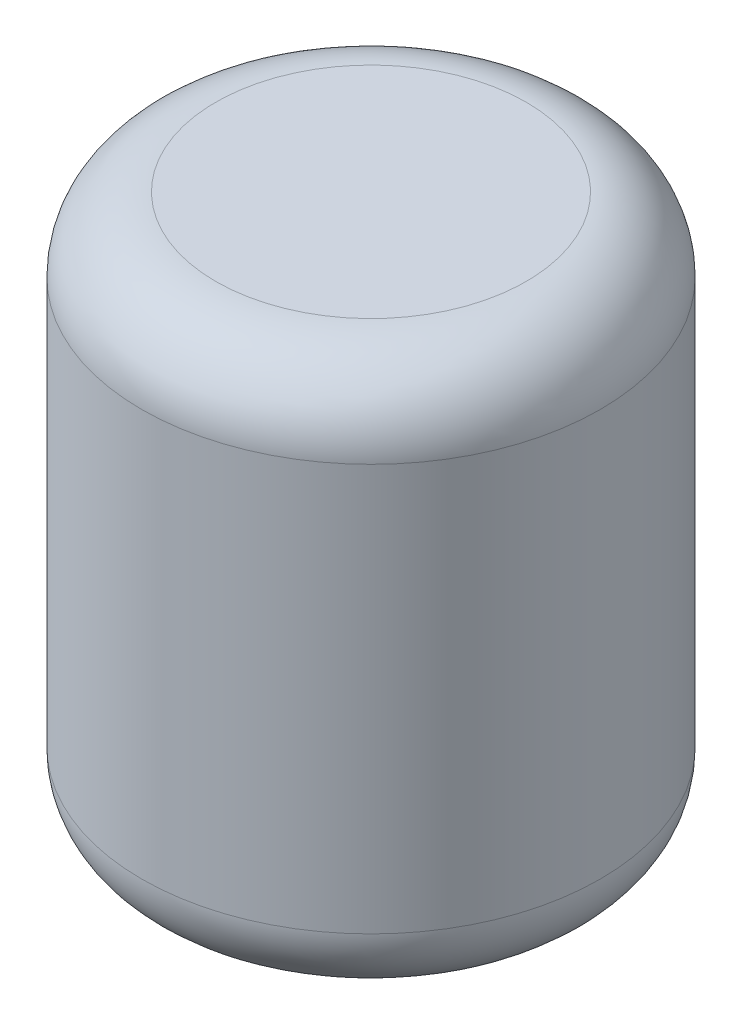
from build123d import *

# Parameters (mm, degrees)
SKIZZE1_R                       = 31
AUFSATZ_LINEAR_AUSTRAGEN1_DEPTH = 37.5
VERRUNDUNG1_R                   = 10


with BuildPart() as part:
    # Skizze1 → Aufsatz-Linear austragen1 (new body, symmetric)
    with BuildSketch(Plane(origin=(0, 0, 0), x_dir=(1, 0, 0), z_dir=(0, 1, 0))):
        Circle(SKIZZE1_R)
    extrude(amount=AUFSATZ_LINEAR_AUSTRAGEN1_DEPTH, both=True)

    # Verrundung1
    verrundung1_edges = [part.edges().sort_by_distance(p)[0] for p in [
        (-31, -37.5, 0),
        (-31, 37.5, 0),
    ]]
    fillet(verrundung1_edges, radius=VERRUNDUNG1_R)


solid = part.part
